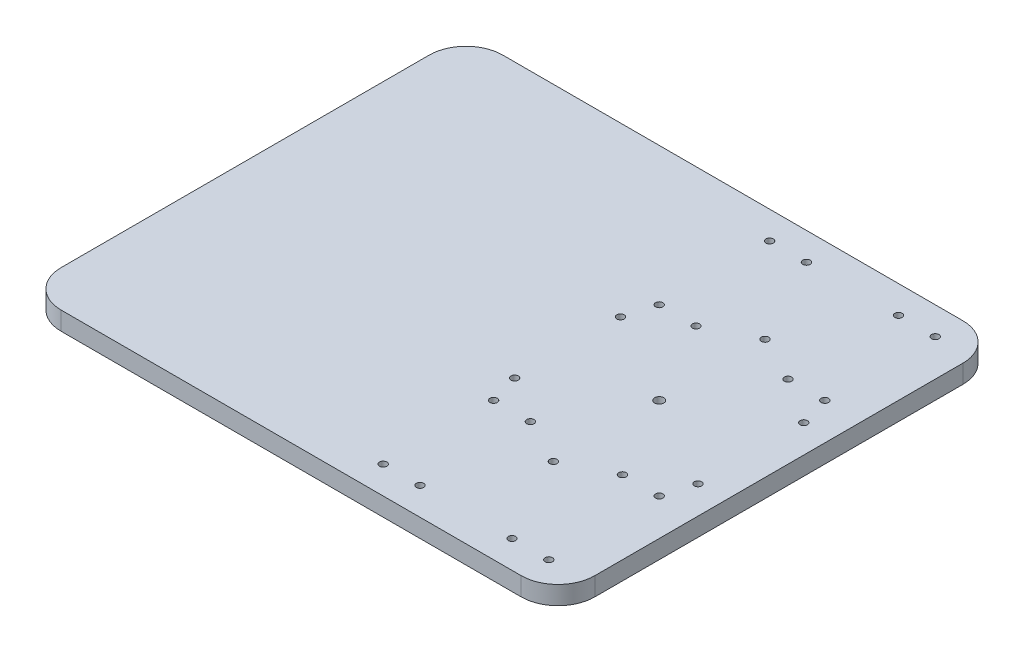
from build123d import *

# Parameters (mm, degrees)
SKETCH1_R           = 2
SKETCH1_R_2         = 2.5
BOSS_EXTRUDE1_DEPTH = 10


with BuildPart() as part:
    # Sketch1 → Boss-Extrude1 (new body)
    with BuildSketch(Plane(origin=(0, 0, 0), x_dir=(1, 0, 0), z_dir=(0, 1, 0))):
        with BuildLine():
            Line((-205, 120), (45, 120))
            ThreePointArc((45, 120), (59.142135624, 114.142135624), (65, 100))
            Line((65, 100), (65, -100))
            ThreePointArc((65, -100), (59.142135624, -114.142135624), (45, -120))
            Line((45, -120), (-205, -120))
            ThreePointArc((-205, -120), (-219.142135624, -114.142135624), (-225, -100))
            Line((-225, -100), (-225, 100))
            ThreePointArc((-225, 100), (-219.142135624, 114.142135624), (-205, 120))
        make_face()
        with Locations((0, -57.5)):
            Circle(SKETCH1_R, mode=Mode.SUBTRACT)
        with Locations((-49.796460718, -28.75)):
            Circle(SKETCH1_R, mode=Mode.SUBTRACT)
        with Locations((-49.796460718, 28.75)):
            Circle(SKETCH1_R, mode=Mode.SUBTRACT)
        with Locations((0, 57.5)):
            Circle(SKETCH1_R, mode=Mode.SUBTRACT)
        with Locations((49.796460718, 28.75)):
            Circle(SKETCH1_R, mode=Mode.SUBTRACT)
        with Locations((49.796460718, -28.75)):
            Circle(SKETCH1_R, mode=Mode.SUBTRACT)
        Circle(SKETCH1_R_2, mode=Mode.SUBTRACT)
        with Locations((-45, 105)):
            Circle(SKETCH1_R, mode=Mode.SUBTRACT)
        with Locations((-25, 105)):
            Circle(SKETCH1_R, mode=Mode.SUBTRACT)
        with Locations((25, 105)):
            Circle(SKETCH1_R, mode=Mode.SUBTRACT)
        with Locations((45, 105)):
            Circle(SKETCH1_R, mode=Mode.SUBTRACT)
        with Locations((-45, 45)):
            Circle(SKETCH1_R, mode=Mode.SUBTRACT)
        with Locations((-25, 45)):
            Circle(SKETCH1_R, mode=Mode.SUBTRACT)
        with Locations((25, 45)):
            Circle(SKETCH1_R, mode=Mode.SUBTRACT)
        with Locations((45, 45)):
            Circle(SKETCH1_R, mode=Mode.SUBTRACT)
        with Locations((-45, -45)):
            Circle(SKETCH1_R, mode=Mode.SUBTRACT)
        with Locations((-25, -45)):
            Circle(SKETCH1_R, mode=Mode.SUBTRACT)
        with Locations((25, -45)):
            Circle(SKETCH1_R, mode=Mode.SUBTRACT)
        with Locations((45, -45)):
            Circle(SKETCH1_R, mode=Mode.SUBTRACT)
        with Locations((45, -105)):
            Circle(SKETCH1_R, mode=Mode.SUBTRACT)
        with Locations((25, -105)):
            Circle(SKETCH1_R, mode=Mode.SUBTRACT)
        with Locations((-25, -105)):
            Circle(SKETCH1_R, mode=Mode.SUBTRACT)
        with Locations((-45, -105)):
            Circle(SKETCH1_R, mode=Mode.SUBTRACT)
    extrude(amount=BOSS_EXTRUDE1_DEPTH)


solid = part.part
